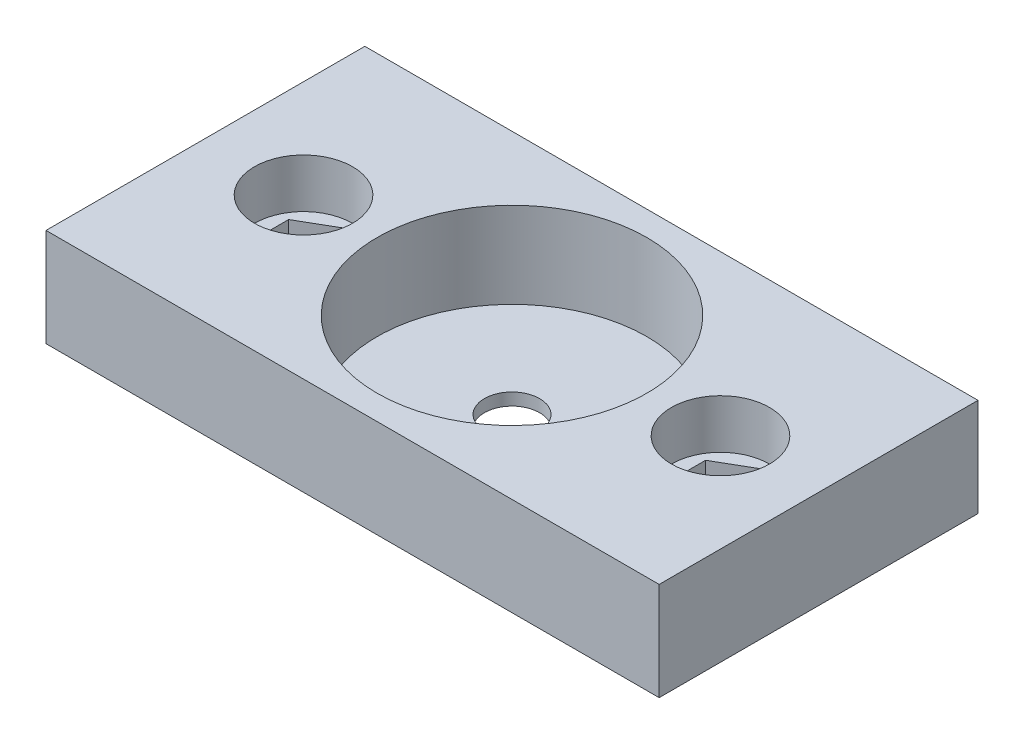
from build123d import *

# Parameters (mm, degrees)
SKETCH1_W                = 50
SKETCH1_H                = 26
BOSS_EXTRUDE1_DEPTH      = 8
SKETCH2_R                = 11
CUT_EXTRUDE1_DEPTH       = 7
SKETCH5_R                = 2.25
CUT_EXTRUDE2_DEPTH       = 2
SKETCH6_R                = 4
CUT_EXTRUDE3_DEPTH       = 4
CUT_EXTRUDE4_DEPTH       = 2.2
M3_CLEARANCE_HOLE1_D     = 3.4
M3_CLEARANCE_HOLE1_DEPTH = 1.8


with BuildPart() as part:
    # Sketch1 → Boss-Extrude1 (new body)
    with BuildSketch(Plane(origin=(0, 0, 0), x_dir=(1, 0, 0), z_dir=(0, 1, 0))):
        Rectangle(SKETCH1_W, SKETCH1_H)
    extrude(amount=BOSS_EXTRUDE1_DEPTH)

    # Sketch2 → Cut-Extrude1 (cut)
    with BuildSketch(Plane(origin=(0, 8, 0), x_dir=(1, 0, 0), z_dir=(0, 1, 0))):
        Circle(SKETCH2_R)
    extrude(amount=-CUT_EXTRUDE1_DEPTH, mode=Mode.SUBTRACT)

    # Sketch5 → Cut-Extrude2 (cut, through all)
    with BuildSketch(Plane(origin=(0, 1, 0), x_dir=(1, 0, 0), z_dir=(0, 1, 0))):
        Circle(SKETCH5_R)
    extrude(amount=-CUT_EXTRUDE2_DEPTH, mode=Mode.SUBTRACT)

    # Sketch6 → Cut-Extrude3 (cut)
    with BuildSketch(Plane(origin=(0, 8, 0), x_dir=(1, 0, 0), z_dir=(0, 1, 0))):
        with Locations((17, 0)):
            Circle(SKETCH6_R)
        with Locations((-17, 0)):
            Circle(SKETCH6_R)
    extrude(amount=-CUT_EXTRUDE3_DEPTH, mode=Mode.SUBTRACT)

    # Sketch7 → Cut-Extrude4 (cut)
    with BuildSketch(Plane(origin=(0, 4, 0), x_dir=(1, 0, 0), z_dir=(0, 1, 0))):
        Polygon((19.875, -1.659882024), (19.875, 1.659882024), (17, 3.319764048), (14.125, 1.659882024), (14.125, -1.659882024), (17, -3.319764048), align=None)
        Polygon((-17, -3.319764048), (-19.875, -1.659882024), (-19.875, 1.659882024), (-17, 3.319764048), (-14.125, 1.659882024), (-14.125, -1.659882024), align=None)
    extrude(amount=-CUT_EXTRUDE4_DEPTH, mode=Mode.SUBTRACT)

    # M3 Clearance Hole1
    with Locations(Plane(origin=(0, 1.8, 0), x_dir=(1, 0, 0), z_dir=(0, 1, 0))):
        with Locations((17, 0), (-17, 0)):
            Hole(M3_CLEARANCE_HOLE1_D / 2, depth=M3_CLEARANCE_HOLE1_DEPTH)


solid = part.part
